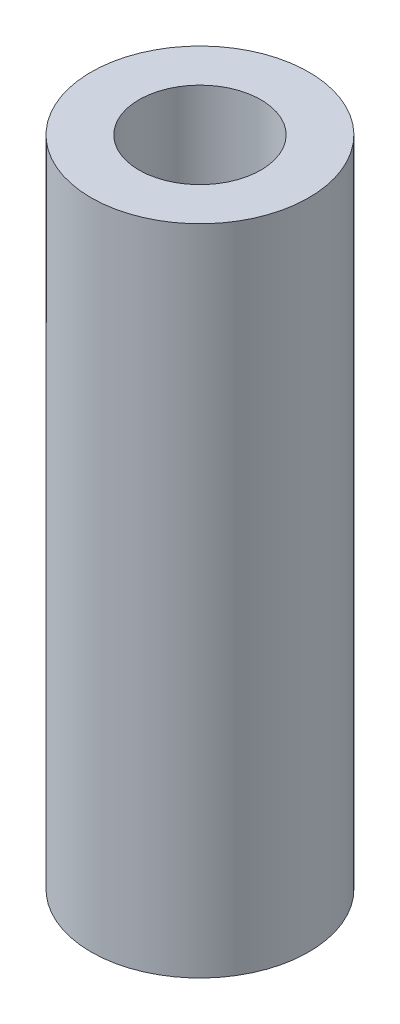
from build123d import *

# Parameters (mm, degrees)
SKETCH1_R           = 2.5
SKETCH1_R_2         = 1.4
BOSS_EXTRUDE1_DEPTH = 15


with BuildPart() as part:
    # Sketch1 → Boss-Extrude1 (new body)
    with BuildSketch(Plane(origin=(0, 0, 0), x_dir=(1, 0, 0), z_dir=(0, 1, 0))):
        Circle(SKETCH1_R)
        Circle(SKETCH1_R_2, mode=Mode.SUBTRACT)
    extrude(amount=BOSS_EXTRUDE1_DEPTH)


solid = part.part
